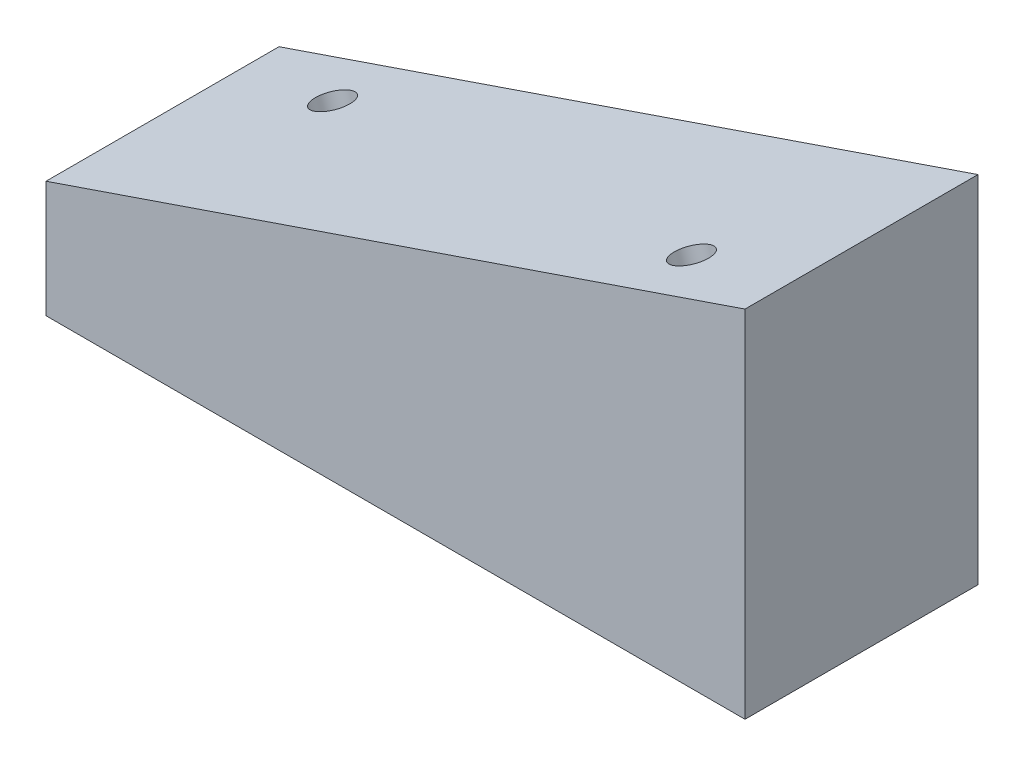
from build123d import *

# Parameters (mm, degrees)
BOSS_EXTRUDE1_DEPTH         = 50.8
F_3_8_16_TAPPED_HOLE1_D     = 7.9375
F_3_8_16_TAPPED_HOLE1_DEPTH = 25.4
F_3_8_16_TAPPED_HOLE1_TIP   = 2.384665582
F_3_8_16_TAPPED_HOLE2_D     = 7.9375
F_3_8_16_TAPPED_HOLE2_DEPTH = 25.4
F_3_8_16_TAPPED_HOLE2_TIP   = 2.384665582


with BuildPart() as part:
    # Sketch1 → Boss-Extrude1 (new body)
    with BuildSketch(Plane.XY):
        Polygon((-76.2, 0), (76.2, 0), (76.2, 77.459343803), (-76.2, 25.4), align=None)
    extrude(amount=-BOSS_EXTRUDE1_DEPTH)

    # 3/8-16 Tapped Hole1
    with Locations(Plane(origin=(-15.732418717, 46.055528891, 0), x_dir=(0.946311265, 0.323256847, 0), z_dir=(-0.323256847, 0.946311265, 0))):
        with Locations((-38.143756412, 38.1), (71.393743588, 12.7)):
            Hole(F_3_8_16_TAPPED_HOLE1_D / 2, depth=F_3_8_16_TAPPED_HOLE1_DEPTH)
            with Locations((0, 0, -(F_3_8_16_TAPPED_HOLE1_DEPTH + F_3_8_16_TAPPED_HOLE1_TIP / 2))):  # 118° drill point
                Cone(0, F_3_8_16_TAPPED_HOLE1_D / 2, F_3_8_16_TAPPED_HOLE1_TIP, mode=Mode.SUBTRACT)

    # 3/8-16 Tapped Hole2
    with Locations(Plane(origin=(0, 0, 0), x_dir=(-1, 0, 0), z_dir=(0, -1, 0))):
        with Locations((38.1, 25.4), (-38.1, 25.4)):
            Hole(F_3_8_16_TAPPED_HOLE2_D / 2, depth=F_3_8_16_TAPPED_HOLE2_DEPTH)
            with Locations((0, 0, -(F_3_8_16_TAPPED_HOLE2_DEPTH + F_3_8_16_TAPPED_HOLE2_TIP / 2))):  # 118° drill point
                Cone(0, F_3_8_16_TAPPED_HOLE2_D / 2, F_3_8_16_TAPPED_HOLE2_TIP, mode=Mode.SUBTRACT)


solid = part.part
